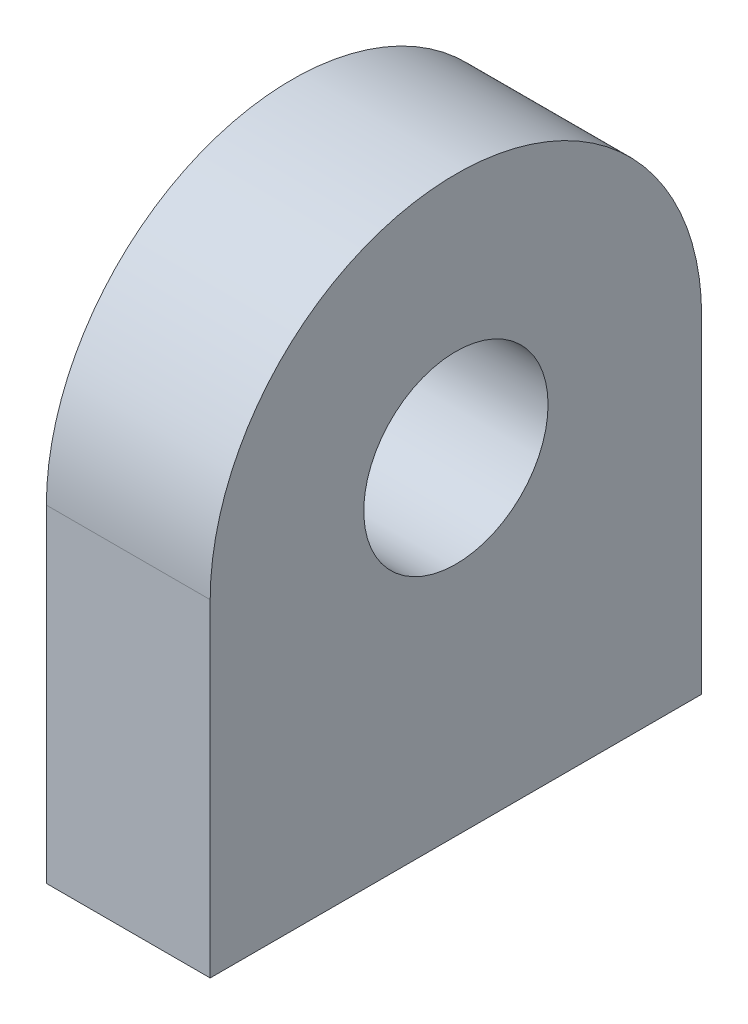
from build123d import *

# Parameters (mm, degrees)
SKETCH1_R           = 14.2875
BOSS_EXTRUDE1_DEPTH = 12.7


with BuildPart() as part:
    # Sketch1 → Boss-Extrude1 (new body, symmetric)
    with BuildSketch(Plane(origin=(0, 0, 0), x_dir=(0, 0, -1), z_dir=(1, 0, 0))):
        with BuildLine():
            Line((-38.1, 0), (38.1, 0))
            Line((38.1, 0), (38.1, 50.8))
            ThreePointArc((38.1, 50.8), (0, 88.9), (-38.1, 50.8))
            Line((-38.1, 50.8), (-38.1, 0))
        make_face()
        with Locations((0, 50.8)):
            Circle(SKETCH1_R, mode=Mode.SUBTRACT)
    extrude(amount=BOSS_EXTRUDE1_DEPTH, both=True)


solid = part.part
